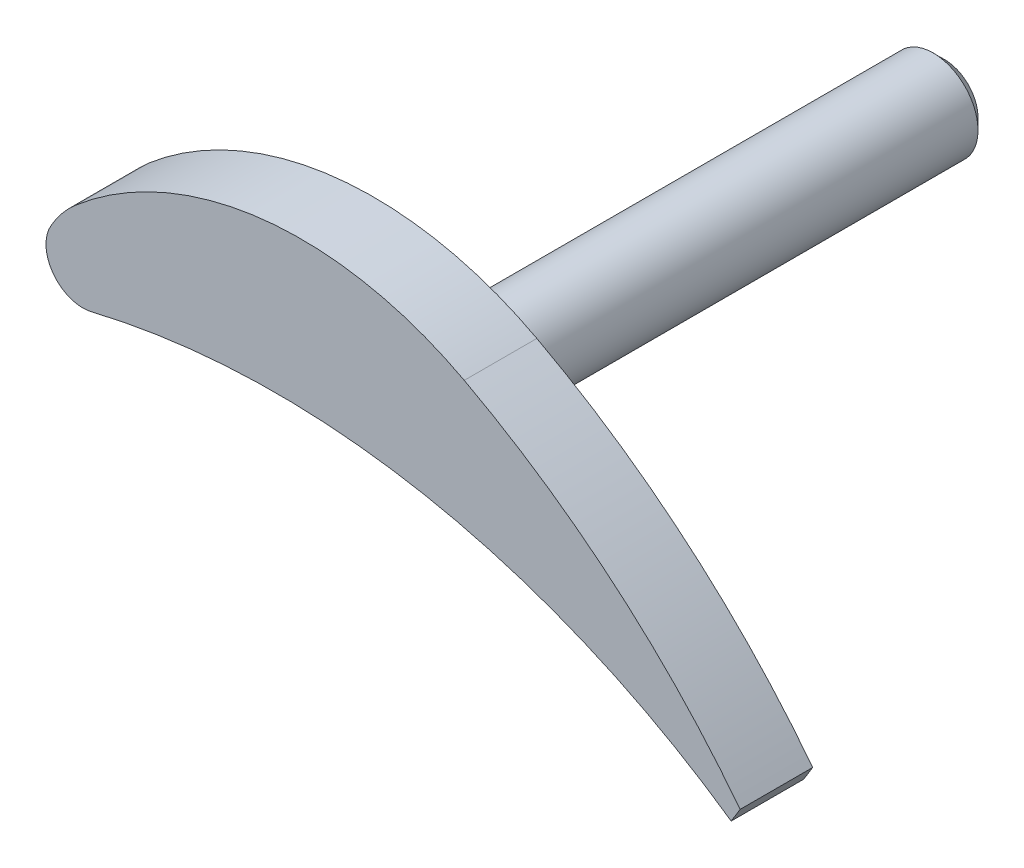
from build123d import *

# Parameters (mm, degrees)
BOSS_EXTRUDE1_DEPTH = 6.5
SKETCH2_R           = 4
BOSS_EXTRUDE2_DEPTH = 40.8
CHAMFER1_SIZE       = 1


with BuildPart() as part:
    # Sketch1 → Boss-Extrude1 (new body)
    with BuildSketch(Plane.XY):
        with BuildLine():
            Line((28.196852764, -18.321256673), (29, -17.010639502))
            ThreePointArc((29, -17.010639502), (17.75919782, -5.237578059), (4.294710806, 3.909454184))
            ThreePointArc((4.294710806, 3.909454184), (-13.701993595, 7.383969683), (-30.515502146, 0.086055087))
            ThreePointArc((-30.515502146, 0.086055087), (-31.755615747, -1.187280745), (-32.750708825, -2.660052163))
            ThreePointArc((-32.750708825, -2.660052163), (-32.488602214, -6.256255028), (-29.091806444, -7.465863814))
            ThreePointArc((-29.091806444, -7.465863814), (0.718290474, -6.741295906), (28.196852764, -18.321256673))
        make_face()
    extrude(amount=BOSS_EXTRUDE1_DEPTH)

    # Sketch2 → Boss-Extrude2 (add)
    with BuildSketch(Plane(origin=(0, 0, 0), x_dir=(-1, 0, 0), z_dir=(0, 0, -1))):
        Circle(SKETCH2_R)
    extrude(amount=BOSS_EXTRUDE2_DEPTH)

    # Chamfer1
    chamfer1_edges = [part.edges().sort_by_distance(p)[0] for p in [
        (4, 0, -40.8),
    ]]
    chamfer(chamfer1_edges, length=CHAMFER1_SIZE)


solid = part.part
